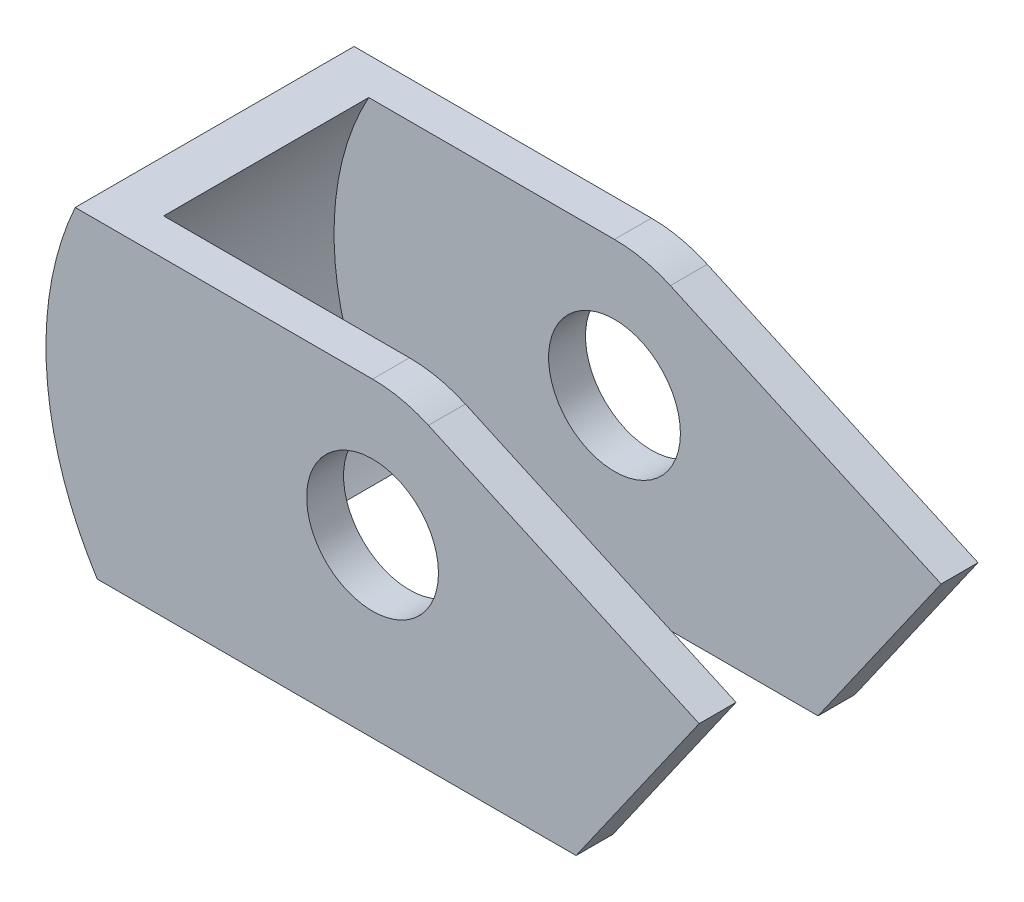
from build123d import *

# Parameters (mm, degrees)
SKETCH1_R           = 14.2875
BOSS_EXTRUDE1_DEPTH = 8
BOSS_EXTRUDE2_START = -44.45
BOSS_EXTRUDE2_DEPTH = 44.45


with BuildPart() as part:
    # Sketch1 → Boss-Extrude1 (new body)
    with BuildSketch(Plane.XY):
        with BuildLine():
            ThreePointArc((12.115221133, 26.66419084), (6.19799028, 28.624160647), (0, 29.2875))
            Line((0, 29.2875), (-64.458376831, 29.2875))
            ThreePointArc((-64.458376831, 29.2875), (-70.622257624, -5.013654168), (-59.674366356, -38.1))
            Line((-59.674366356, -38.1), (44.122092794, -38.1))
            Line((44.122092794, -38.1), (70.8, 0))
            Line((70.8, 0), (12.115221133, 26.66419084))
        make_face()
        Circle(SKETCH1_R, mode=Mode.SUBTRACT)
    boss_extrude1 = extrude(amount=BOSS_EXTRUDE1_DEPTH)

    # Sketch1_3 → Boss-Extrude2 (add)
    with BuildSketch(Plane.XY.offset(BOSS_EXTRUDE2_START)):
        with BuildLine():
            Line((-59.674366356, -38.1), (-47.381747541, -38.1))
            ThreePointArc((-47.381747541, -38.1), (-58.074384746, -18.000162122), (-60.623939927, 4.62362495))
            ThreePointArc((-60.623939927, 4.62362495), (-58.272376031, 17.348492489), (-53.281163123, 29.2875))
            Line((-53.281163123, 29.2875), (-64.458376831, 29.2875))
            ThreePointArc((-64.458376831, 29.2875), (-69.196434445, 14.983105825), (-70.8, 0))
            ThreePointArc((-70.8, 0), (-67.96169928, -19.845589711), (-59.674366356, -38.1))
        make_face()
    extrude(amount=BOSS_EXTRUDE2_DEPTH)

    # Mirror1: Boss-Extrude1 across plane
    add(boss_extrude1.mirror(Plane(origin=(0, 0, -22.225), x_dir=(1, 0, 0), z_dir=(0, 0, -1))))


solid = part.part
